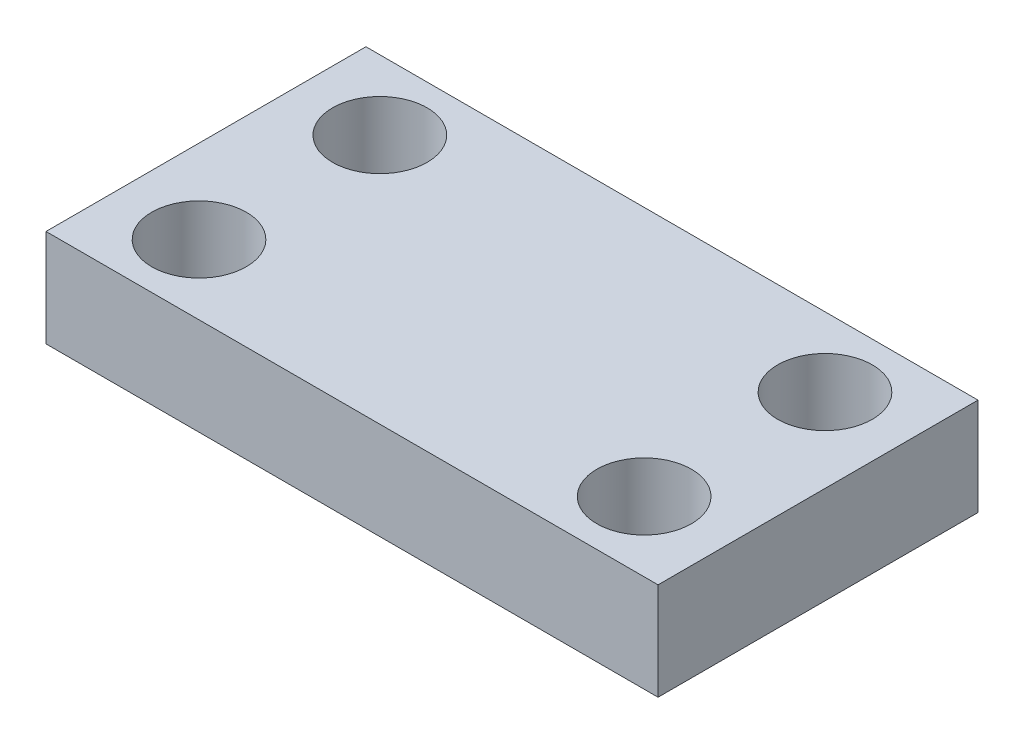
from build123d import *

# Parameters (mm, degrees)
SKETCH1_W           = 22
SKETCH1_H           = 11.5
SKETCH1_R           = 1.7
BOSS_EXTRUDE1_DEPTH = 3.5


with BuildPart() as part:
    # Sketch1 → Boss-Extrude1 (new body)
    with BuildSketch(Plane(origin=(0, 0, 0), x_dir=(1, 0, 0), z_dir=(0, 1, 0))):
        with Locations((11, 5.75)):
            Rectangle(SKETCH1_W, SKETCH1_H)
        with Locations((3, 2.5)):
            Circle(SKETCH1_R, mode=Mode.SUBTRACT)
        with Locations((3, 9)):
            Circle(SKETCH1_R, mode=Mode.SUBTRACT)
        with Locations((19, 9)):
            Circle(SKETCH1_R, mode=Mode.SUBTRACT)
        with Locations((19, 2.5)):
            Circle(SKETCH1_R, mode=Mode.SUBTRACT)
    extrude(amount=BOSS_EXTRUDE1_DEPTH)


solid = part.part
